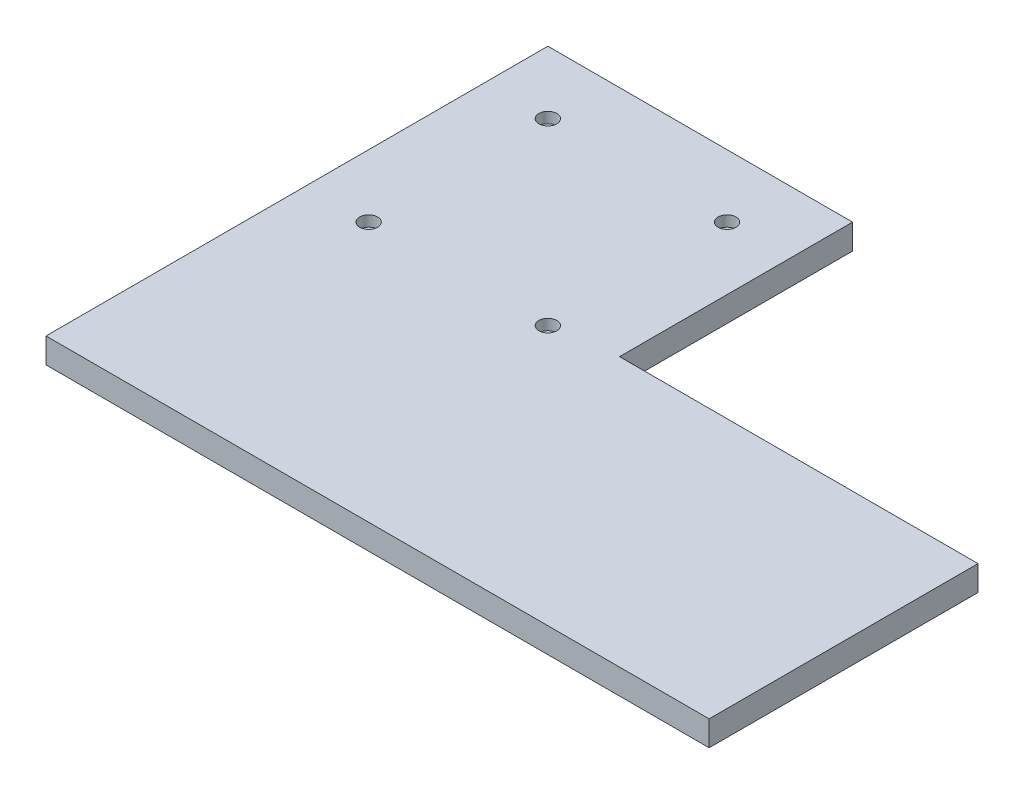
from build123d import *

# Parameters (mm, degrees)
BOSS_EXTRUDE1_DEPTH = 7
SKETCH2_R           = 2.5
CUT_EXTRUDE2_DEPTH  = 3


with BuildPart() as part:
    # Sketch1 → Boss-Extrude1 (new body)
    with BuildSketch(Plane(origin=(0, 0, 0), x_dir=(1, 0, 0), z_dir=(0, 1, 0))):
        Polygon((14.318293597, 31.894904459), (-70.681706403, 31.894904459), (-70.681706403, -108.105095541), (114.318293597, -108.105095541), (114.318293597, -33.105095541), (14.318293597, -33.105095541), align=None)
    extrude(amount=BOSS_EXTRUDE1_DEPTH)

    # Sketch2 → Cut-Extrude2 (cut)
    with BuildSketch(Plane(origin=(0, 7, 0), x_dir=(1, 0, 0), z_dir=(0, 1, 0))):
        with Locations((-53.181706403, 14.394904459)):
            Circle(SKETCH2_R)
        with Locations((-3.181706403, 14.394904459)):
            Circle(SKETCH2_R)
        with Locations((-3.181706403, -35.605095541)):
            Circle(SKETCH2_R)
        with Locations((-53.181706403, -35.605095541)):
            Circle(SKETCH2_R)
    extrude(amount=-CUT_EXTRUDE2_DEPTH, mode=Mode.SUBTRACT)


solid = part.part
